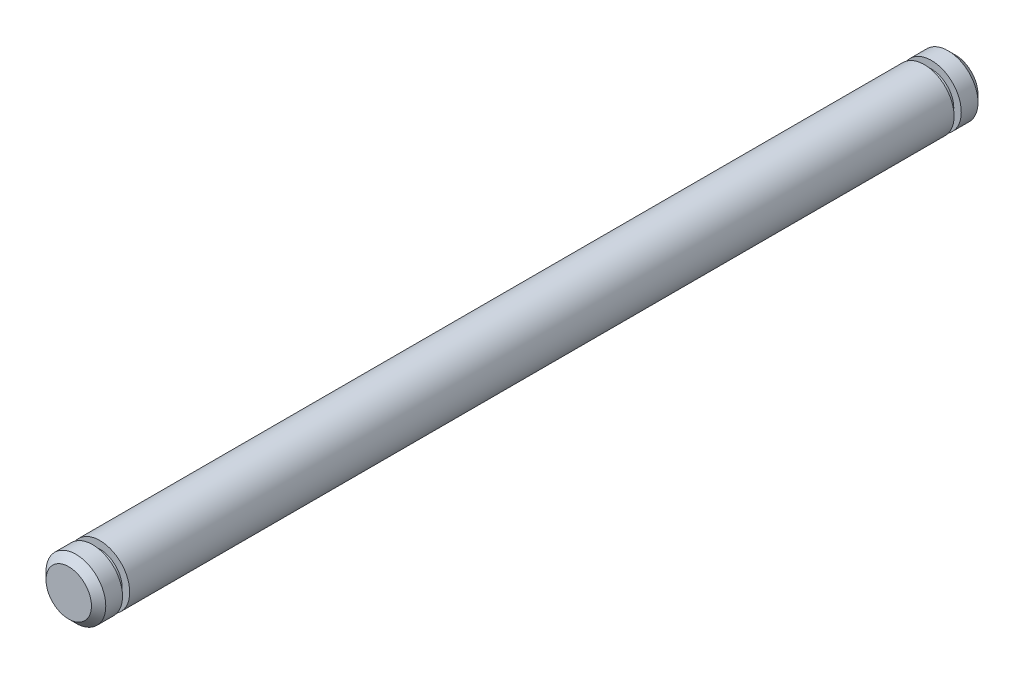
from build123d import *

# Parameters (mm, degrees)
SKETCH1_R                = 1.5875
BOSS_EXTRUDE1_DEPTH      = 21.89226
SKETCH2_R                = 1.19126
BOSS_EXTRUDE2_DEPTH      = 0.381
SKETCH3_R                = 1.5875
BOSS_EXTRUDE3_DEPTH      = 1.27
CHAMFER1_SIZE            = 0.381
CHAMFER1_OF_MIRROR1_SIZE = 0.381


with BuildPart() as part:
    # Sketch1 → Boss-Extrude1 (new body, symmetric)
    with BuildSketch(Plane.XY):
        Circle(SKETCH1_R)
    extrude(amount=BOSS_EXTRUDE1_DEPTH, both=True)

    # Sketch2 → Boss-Extrude2 (add)
    with BuildSketch(Plane.XY.offset(21.89226)):
        Circle(SKETCH2_R)
    boss_extrude2 = extrude(amount=BOSS_EXTRUDE2_DEPTH)

    # Sketch3 → Boss-Extrude3 (add)
    with BuildSketch(Plane.XY.offset(22.27326)):
        Circle(SKETCH3_R)
    boss_extrude3 = extrude(amount=BOSS_EXTRUDE3_DEPTH)

    # Chamfer1
    chamfer1_edges = [part.edges().sort_by_distance(p)[0] for p in [
        (-1.5875, 0, 23.54326),
    ]]
    chamfer(chamfer1_edges, length=CHAMFER1_SIZE)

    # Mirror1: Boss-Extrude2, Boss-Extrude3 across plane
    add(boss_extrude2.mirror(Plane.XY))
    add(boss_extrude3.mirror(Plane.XY))

    # Chamfer1 of Mirror1
    chamfer1_of_mirror1_edges = [part.edges().sort_by_distance(p)[0] for p in [
        (-1.5875, 0, -23.54326),
    ]]
    chamfer(chamfer1_of_mirror1_edges, length=CHAMFER1_OF_MIRROR1_SIZE)


solid = part.part
